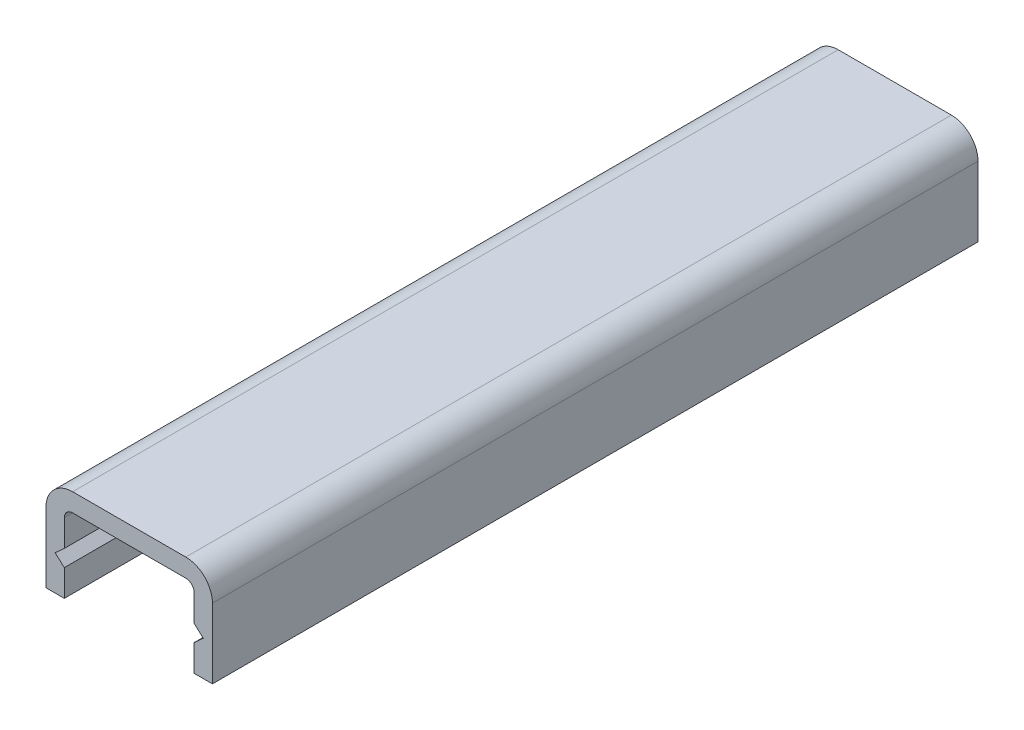
from build123d import *

# Parameters (mm, degrees)
EXTRUSION1_DEPTH = 46


with BuildPart() as part:
    # Esquisse1 → Extrusion1 (new body)
    with BuildSketch(Plane.XY):
        with BuildLine():
            Line((1.6, 5.8), (8.4, 5.8))
            ThreePointArc((8.4, 5.8), (9.53137085, 5.33137085), (10, 4.2))
            Line((10, 4.2), (10, 0))
            Line((10, 0), (8.9, 0))
            Line((8.9, 0), (8.9, 1.6))
            Line((8.9, 1.6), (9.45, 2.1))
            Line((9.45, 2.1), (8.9, 2.6))
            Line((8.9, 2.6), (8.9, 4.2))
            ThreePointArc((8.9, 4.2), (8.753553391, 4.553553391), (8.4, 4.7))
            Line((8.4, 4.7), (1.6, 4.7))
            ThreePointArc((1.6, 4.7), (1.246446609, 4.553553391), (1.1, 4.2))
            Line((1.1, 4.2), (1.1, 2.6))
            Line((1.1, 2.6), (0.55, 2.1))
            Line((0.55, 2.1), (1.1, 1.6))
            Line((1.1, 1.6), (1.1, 0))
            Line((1.1, 0), (0, 0))
            Line((0, 0), (0, 4.2))
            ThreePointArc((0, 4.2), (0.46862915, 5.33137085), (1.6, 5.8))
        make_face()
    extrude(amount=EXTRUSION1_DEPTH)


solid = part.part
